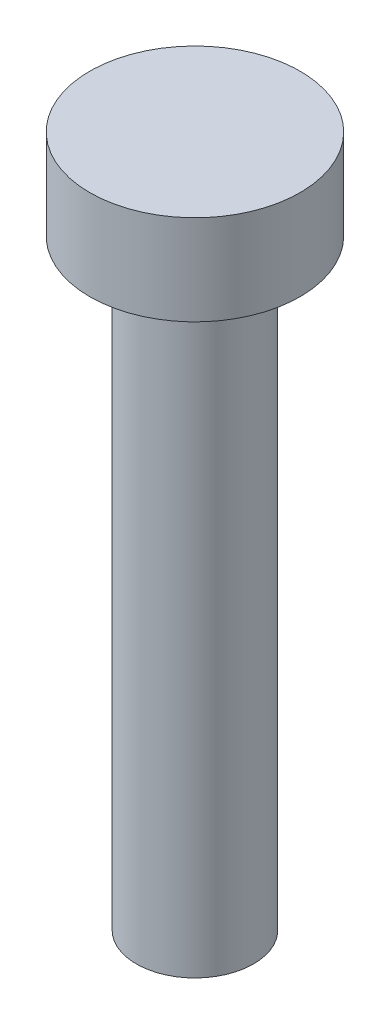
from build123d import *

# Parameters (mm, degrees)
SKETCH1_R           = 3.5
BOSS_EXTRUDE1_DEPTH = 3
SKETCH2_R           = 1.95
BOSS_EXTRUDE2_DEPTH = 20


with BuildPart() as part:
    # Sketch1 → Boss-Extrude1 (new body)
    with BuildSketch(Plane(origin=(0, 0, 0), x_dir=(1, 0, 0), z_dir=(0, 1, 0))):
        Circle(SKETCH1_R)
    extrude(amount=BOSS_EXTRUDE1_DEPTH)

    # Sketch2 → Boss-Extrude2 (add)
    with BuildSketch(Plane.XZ):
        Circle(SKETCH2_R)
    extrude(amount=BOSS_EXTRUDE2_DEPTH)


solid = part.part
